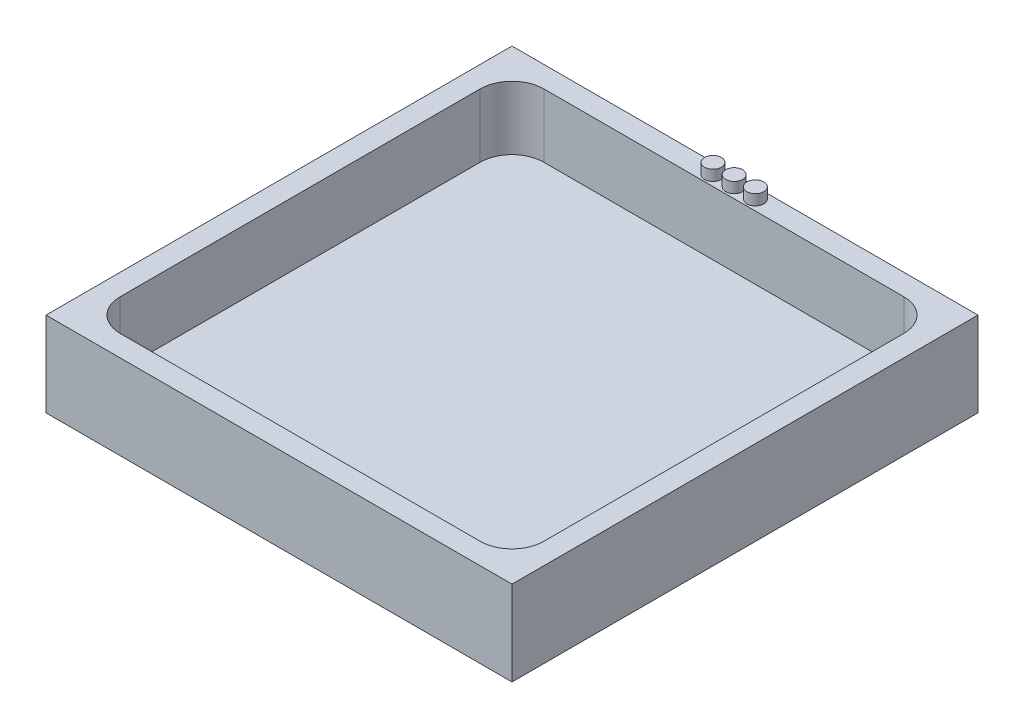
from build123d import *

# Parameters (mm, degrees)
SKETCH1_W           = 20
SKETCH1_H           = 20
BOSS_EXTRUDE2_DEPTH = 1
SKETCH1_6_W         = 22
SKETCH1_6_H         = 22
SKETCH1_6_W_2       = 20
SKETCH1_6_H_2       = 20
BOSS_EXTRUDE3_DEPTH = 4
SKETCH2_R           = 0.4
BOSS_EXTRUDE4_DEPTH = 0.5
FILLET1_R           = 1.5


with BuildPart() as part:
    # Sketch1 → Boss-Extrude2 (new body)
    with BuildSketch(Plane(origin=(0, 0, 0), x_dir=(1, 0, 0), z_dir=(0, 1, 0))):
        Rectangle(SKETCH1_W, SKETCH1_H)
    extrude(amount=BOSS_EXTRUDE2_DEPTH)

    # Sketch1_6 → Boss-Extrude3 (add)
    with BuildSketch(Plane(origin=(0, 0, 0), x_dir=(1, 0, 0), z_dir=(0, 1, 0))):
        Rectangle(SKETCH1_6_W, SKETCH1_6_H)
        Rectangle(SKETCH1_6_W_2, SKETCH1_6_H_2, mode=Mode.SUBTRACT)
    extrude(amount=BOSS_EXTRUDE3_DEPTH)

    # Sketch2 → Boss-Extrude4 (add)
    with BuildSketch(Plane(origin=(0, 4, 0), x_dir=(1, 0, 0), z_dir=(0, 1, 0))):
        with Locations((0, 10.490155688)):
            Circle(SKETCH2_R)
        with Locations((1, 10.490155688)):
            Circle(SKETCH2_R)
        with Locations((-1, 10.490155688)):
            Circle(SKETCH2_R)
    extrude(amount=BOSS_EXTRUDE4_DEPTH)

    # Fillet1
    fillet1_edges = [part.edges().sort_by_distance(p)[0] for p in [
        (10, 2.5, -10),
        (-10, 2.5, -10),
        (-10, 2.5, 10),
        (10, 2.5, 10),
    ]]
    fillet(fillet1_edges, radius=FILLET1_R)


solid = part.part
